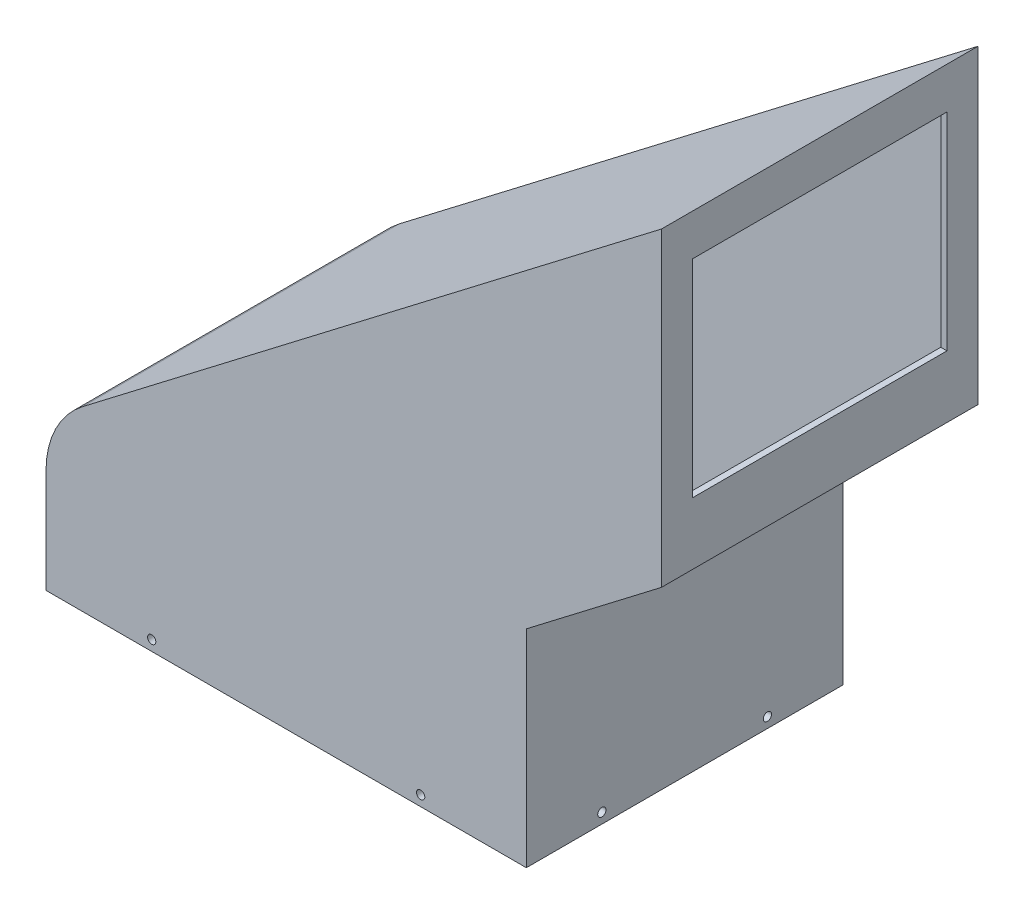
from build123d import *

# Parameters (mm, degrees)
RESSALTO_EXTRUS_O1_DEPTH = 153
CASCA1_T                 = -3
CORTE_EXTRUS_O1_REACH    = 299.454
ESBO_O4_W                = 123
ESBO_O4_H                = 100
ESBO_O5_R                = 2
CORTE_EXTRUS_O2_DEPTH    = 154
ESBO_O6_R                = 2
CORTE_EXTRUS_O3_DEPTH    = 233.16


with BuildPart() as part:
    # Esboço1 → Ressalto-extrusão1 (new body)
    with BuildSketch(Plane.XY):
        with BuildLine():
            Line((0, 0), (0, 50))
            ThreePointArc((0, 50), (4.650495405, 69.922787932), (17.640776843, 85.72776103))
            Line((17.640776843, 85.72776103), (297.45381486, 300))
            Line((297.45381486, 300), (297.45381486, 150))
            Line((297.45381486, 150), (232.16, 100))
            Line((232.16, 100), (232.16, 0))
            Line((232.16, 0), (0, 0))
        make_face()
    extrude(amount=RESSALTO_EXTRUS_O1_DEPTH)

    # Casca1
    casca1_openings = [part.faces().sort_by_distance(p)[0] for p in [
        (116.08, 0, 76.5),
    ]]
    offset(amount=CASCA1_T, openings=casca1_openings, kind=Kind.INTERSECTION)

    # Esboço4 → Corte-extrusão1 (cut, up to next)
    with BuildSketch(Plane(origin=(297.45381486, 0, 0), x_dir=(0, 0, -1), z_dir=(1, 0, 0)), mode=Mode.PRIVATE) as corte_extrus_o1_sk1:
        with Locations((-76.5, 230)):
            Rectangle(ESBO_O4_W, ESBO_O4_H)
    corte_extrus_o1_tool1 = extrude(corte_extrus_o1_sk1.sketch, amount=-CORTE_EXTRUS_O1_REACH, mode=Mode.PRIVATE) & part.part
    add(corte_extrus_o1_tool1.solids().sort_by_distance((297.453815, 230, 76.5))[0], mode=Mode.SUBTRACT)

    # Esboço5 → Corte-extrusão2 (cut, through all)
    with BuildSketch(Plane.XY.offset(153)):
        with Locations((181.08, 5)):
            Circle(ESBO_O5_R)
        with Locations((51.08, 5)):
            Circle(ESBO_O5_R)
    extrude(amount=-CORTE_EXTRUS_O2_DEPTH, mode=Mode.SUBTRACT)

    # Esboço6 → Corte-extrusão3 (cut, through all)
    with BuildSketch(Plane(origin=(232.16, 0, 0), x_dir=(0, 0, -1), z_dir=(1, 0, 0))):
        with Locations((-36.5, 5)):
            Circle(ESBO_O6_R)
        with Locations((-116.5, 5)):
            Circle(ESBO_O6_R)
    extrude(amount=-CORTE_EXTRUS_O3_DEPTH, mode=Mode.SUBTRACT)


solid = part.part
